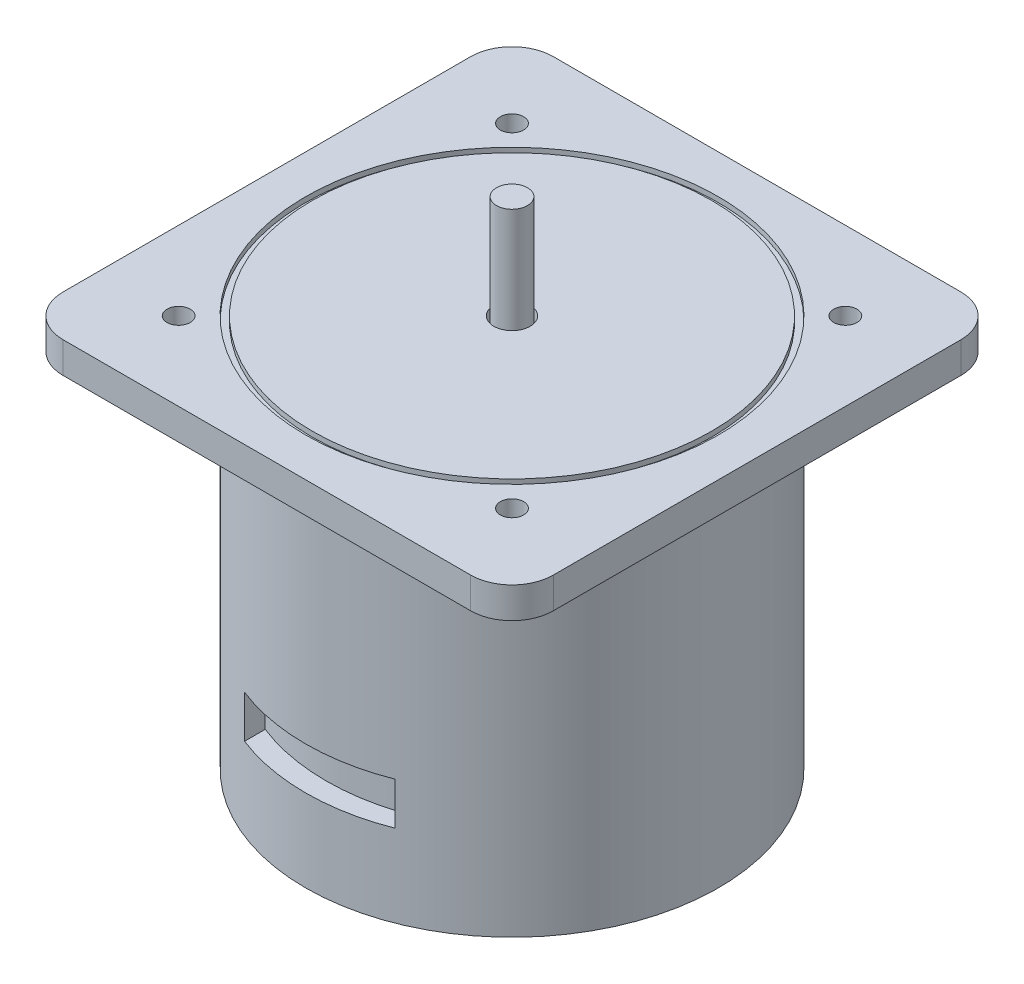
from build123d import *

# Parameters (mm, degrees)
SKETCH1_R                 = 40
BOSS_EXTRUDE1_DEPTH       = 70
SKETCH2_W                 = 95
SKETCH2_H                 = 95
BOSS_EXTRUDE2_DEPTH       = 6
SKETCH3_R                 = 40
SKETCH3_R_2               = 38.709273032
CUT_EXTRUDE1_DEPTH        = 1
SKETCH4_R                 = 3
BOSS_EXTRUDE3_DEPTH       = 20
FILLET1_R                 = 8
SKETCH6_R                 = 3.519560707
SKETCH6_R_2               = 3
CUT_EXTRUDE3_DEPTH        = 5
CUT_EXTRUDE4_REACH        = 123.169
CUT_EXTRUDE4_START_RADIUS = 40
CUT_EXTRUDE4_END_RADIUS   = 40
SKETCH8_W                 = 29.147137568
SKETCH8_H                 = 8.22098752
BOSS_EXTRUDE5_DEPTH       = 4
SKETCH10_R                = 2.25
CUT_EXTRUDE5_DEPTH        = 34


with BuildPart() as part:
    # Sketch1 → Boss-Extrude1 (new body)
    with BuildSketch(Plane(origin=(0, 0, 0), x_dir=(1, 0, 0), z_dir=(0, 1, 0))):
        with Locations(Location((0, 0, 0), (0, 0, 270))):
            Circle(SKETCH1_R)
    extrude(amount=BOSS_EXTRUDE1_DEPTH)

    # Sketch2 → Boss-Extrude2 (add)
    with BuildSketch(Plane(origin=(0, 70, 0), x_dir=(1, 0, 0), z_dir=(0, 1, 0))):
        Rectangle(SKETCH2_W, SKETCH2_H)
    extrude(amount=BOSS_EXTRUDE2_DEPTH)

    # Sketch3 → Cut-Extrude1 (cut)
    with BuildSketch(Plane(origin=(0, 76, 0), x_dir=(1, 0, 0), z_dir=(0, 1, 0))):
        with Locations(Location((0, 0, 0), (0, 0, 270))):
            Circle(SKETCH3_R)
        with Locations(Location((0, 0, 0), (0, 0, 270))):
            Circle(SKETCH3_R_2, mode=Mode.SUBTRACT)
    extrude(amount=-CUT_EXTRUDE1_DEPTH, mode=Mode.SUBTRACT)

    # Sketch4 → Boss-Extrude3 (add)
    with BuildSketch(Plane(origin=(0, 76, 0), x_dir=(1, 0, 0), z_dir=(0, 1, 0))):
        with Locations(Location((0, 0, 0), (0, 0, 270))):
            Circle(SKETCH4_R)
    extrude(amount=BOSS_EXTRUDE3_DEPTH)

    # Fillet1
    fillet1_edges = [part.edges().sort_by_distance(p)[0] for p in [
        (47.5, 73, 47.5),
        (47.5, 73, -47.5),
        (-47.5, 73, -47.5),
        (-47.5, 73, 47.5),
    ]]
    fillet(fillet1_edges, radius=FILLET1_R)

    # Sketch6 → Cut-Extrude3 (cut)
    with BuildSketch(Plane(origin=(0, 76, 0), x_dir=(1, 0, 0), z_dir=(0, 1, 0))):
        with Locations(Location((0, 0, 0), (0, 0, 270))):
            Circle(SKETCH6_R)
        with Locations(Location((0, 0, 0), (0, 0, 270))):
            Circle(SKETCH6_R_2, mode=Mode.SUBTRACT)
    extrude(amount=-CUT_EXTRUDE3_DEPTH, mode=Mode.SUBTRACT)

    # Cut-Extrude4: from a cylinder face, 123.169 long prism both ways, kept between that surface and its translate by the depth
    cut_extrude4_start = Plane(origin=(0, 20.055809, 0), z_dir=(0, -1, 0)) * Cylinder(CUT_EXTRUDE4_START_RADIUS, 327.338, mode=Mode.PRIVATE)
    cut_extrude4_end = Plane(origin=(0, 20.055809, -4), z_dir=(0, -1, 0)) * Cylinder(CUT_EXTRUDE4_END_RADIUS, 327.338, mode=Mode.PRIVATE)
    # Sketch8 → Cut-Extrude4 (cut, from a surface)
    with BuildSketch(Plane.XY, mode=Mode.PRIVATE) as cut_extrude4_sk1:
        with Locations((0, 20.055809212)):
            Rectangle(SKETCH8_W, SKETCH8_H)
    cut_extrude4_tool1 = extrude(cut_extrude4_sk1.sketch, amount=CUT_EXTRUDE4_REACH, both=True, mode=Mode.PRIVATE)
    add(((cut_extrude4_tool1 & cut_extrude4_start) - cut_extrude4_end).solids().sort_by_distance((0, 20.055809, 35.250652))[0], mode=Mode.SUBTRACT)

    # Sketch9 → Boss-Extrude5 (add)
    with BuildSketch(Plane.XZ):
        with BuildLine():
            ThreePointArc((-25.622676251, -4.384366141), (-27.880429407, -0.093420807), (-25.772900348, 4.273269294))
            Line((-25.772900348, 4.273269294), (-27.319093183, 6.289872554))
            ThreePointArc((-27.319093183, 6.289872554), (-29.604344551, 3.506882349), (-30.422381519, 0))
            ThreePointArc((-30.422381519, 0), (-29.542433802, -3.629669529), (-27.097976665, -6.453397238))
            Line((-27.097976665, -6.453397238), (-25.622676251, -4.384366141))
        make_face()
    boss_extrude5 = extrude(amount=BOSS_EXTRUDE5_DEPTH)

    # Mirror1: Boss-Extrude5 across plane
    add(boss_extrude5.mirror(Plane(origin=(0, 0, 0), x_dir=(0, 0, 1), z_dir=(1, 0, 0))))

    # Sketch10 → Cut-Extrude5 (cut)
    with BuildSketch(Plane(origin=(0, 76, 0), x_dir=(1, 0, 0), z_dir=(0, 1, 0))):
        with Locations(Location((-32.295599691, 32.295599691, 0), (0, 0, 270))):
            Circle(SKETCH10_R)
        with Locations(Location((32.295599691, 32.295599691, 0), (0, 0, 270))):
            Circle(SKETCH10_R)
        with Locations(Location((32.295599691, -32.295599691, 0), (0, 0, 270))):
            Circle(SKETCH10_R)
        with Locations(Location((-32.295599691, -32.295599691, 0), (0, 0, 270))):
            Circle(SKETCH10_R)
    extrude(amount=-CUT_EXTRUDE5_DEPTH, mode=Mode.SUBTRACT)


solid = part.part
